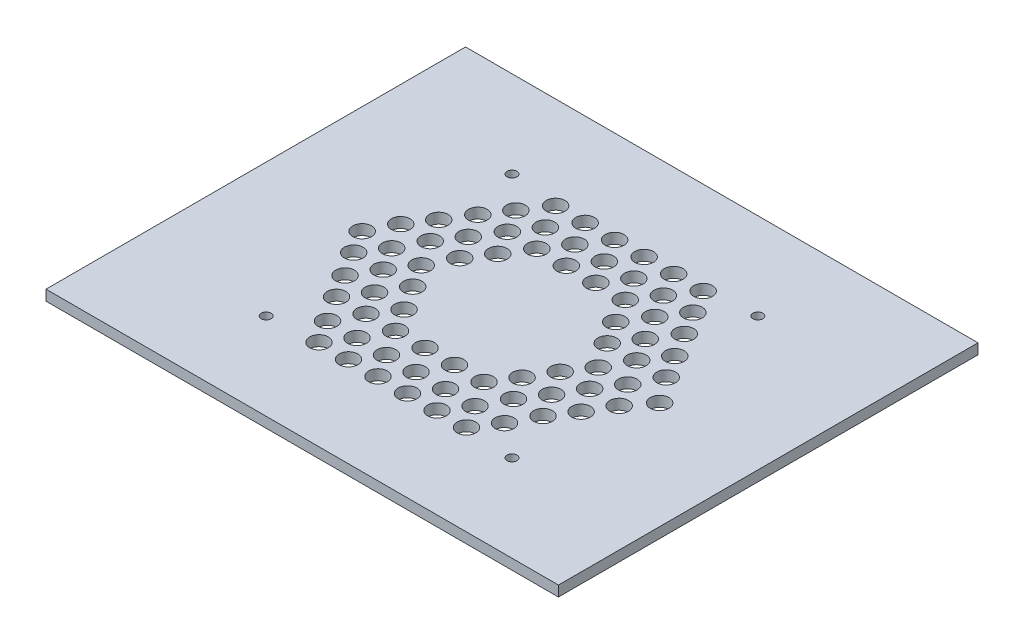
from build123d import *

# Parameters (mm, degrees)
SKETCH1_W           = 156.35
SKETCH1_H           = 128
BOSS_EXTRUDE1_DEPTH = 3.175
SKETCH2_R           = 1.5
CUT_EXTRUDE1_DEPTH  = 10
SKETCH3_R           = 2.8575
CUT_EXTRUDE2_DEPTH  = 10


with BuildPart() as part:
    # Sketch1 → Boss-Extrude1 (new body)
    with BuildSketch(Plane(origin=(0, 0, 0), x_dir=(1, 0, 0), z_dir=(0, 1, 0))):
        with Locations((16.313207547, -20.741037736)):
            Rectangle(SKETCH1_W, SKETCH1_H)
    extrude(amount=BOSS_EXTRUDE1_DEPTH)

    # Sketch2 → Cut-Extrude1 (cut)
    with BuildSketch(Plane.XZ):
        with Locations((-21.186792453, 58.241037736)):
            Circle(SKETCH2_R)
        with Locations((53.813207547, 58.241037736)):
            Circle(SKETCH2_R)
        with Locations((53.813207547, -16.758962264)):
            Circle(SKETCH2_R)
        with Locations((-21.186792453, -16.758962264)):
            Circle(SKETCH2_R)
    extrude(amount=-CUT_EXTRUDE1_DEPTH, mode=Mode.SUBTRACT)

    # Sketch3 → Cut-Extrude2 (cut)
    with BuildSketch(Plane.XZ):
        with Locations((-6.178033112, 57.136048301)):
            Circle(SKETCH3_R)
        with Locations((2.821966888, 57.136048301)):
            Circle(SKETCH3_R)
        with Locations((11.821966888, 57.136048301)):
            Circle(SKETCH3_R)
        with Locations((20.821966888, 57.136048301)):
            Circle(SKETCH3_R)
        with Locations((29.821966888, 57.136048301)):
            Circle(SKETCH3_R)
        with Locations((38.821966888, 57.136048301)):
            Circle(SKETCH3_R)
        with Locations((-10.513543723, 50.195532798)):
            Circle(SKETCH3_R)
        with Locations((-1.513543723, 50.195532798)):
            Circle(SKETCH3_R)
        with Locations((7.486456277, 50.195532798)):
            Circle(SKETCH3_R)
        with Locations((16.486456277, 50.195532798)):
            Circle(SKETCH3_R)
        with Locations((25.486456277, 50.195532798)):
            Circle(SKETCH3_R)
        with Locations((34.486456277, 50.195532798)):
            Circle(SKETCH3_R)
        with Locations((43.486456277, 50.195532798)):
            Circle(SKETCH3_R)
        with Locations((-15.52660687, 42.439711518)):
            Circle(SKETCH3_R)
        with Locations((-6.52660687, 42.439711518)):
            Circle(SKETCH3_R)
        with Locations((2.47339313, 42.439711518)):
            Circle(SKETCH3_R)
        with Locations((11.47339313, 42.439711518)):
            Circle(SKETCH3_R)
        with Locations((20.47339313, 42.439711518)):
            Circle(SKETCH3_R)
        with Locations((29.47339313, 42.439711518)):
            Circle(SKETCH3_R)
        with Locations((38.47339313, 42.439711518)):
            Circle(SKETCH3_R)
        with Locations((47.47339313, 42.439711518)):
            Circle(SKETCH3_R)
        with Locations((-19.862117481, 35.499196015)):
            Circle(SKETCH3_R)
        with Locations((-10.862117481, 35.499196015)):
            Circle(SKETCH3_R)
        with Locations((-1.862117481, 35.499196015)):
            Circle(SKETCH3_R)
        with Locations((34.137882519, 35.499196015)):
            Circle(SKETCH3_R)
        with Locations((43.137882519, 35.499196015)):
            Circle(SKETCH3_R)
        with Locations((52.137882519, 35.499196015)):
            Circle(SKETCH3_R)
        with Locations((-24.594118133, 28.137585821)):
            Circle(SKETCH3_R)
        with Locations((-15.594118133, 28.137585821)):
            Circle(SKETCH3_R)
        with Locations((-6.594118133, 28.137585821)):
            Circle(SKETCH3_R)
        with Locations((38.405881867, 28.137585821)):
            Circle(SKETCH3_R)
        with Locations((47.405881867, 28.137585821)):
            Circle(SKETCH3_R)
        with Locations((56.405881867, 28.137585821)):
            Circle(SKETCH3_R)
        with Locations((-28.929628744, 21.197070319)):
            Circle(SKETCH3_R)
        with Locations((-19.929628744, 21.197070319)):
            Circle(SKETCH3_R)
        with Locations((-10.929628744, 21.197070319)):
            Circle(SKETCH3_R)
        with Locations((43.070371256, 21.197070319)):
            Circle(SKETCH3_R)
        with Locations((52.070371256, 21.197070319)):
            Circle(SKETCH3_R)
        with Locations((-24.942691891, 13.441249039)):
            Circle(SKETCH3_R)
        with Locations((-15.942691891, 13.441249039)):
            Circle(SKETCH3_R)
        with Locations((-6.942691891, 13.441249039)):
            Circle(SKETCH3_R)
        with Locations((38.057308109, 13.441249039)):
            Circle(SKETCH3_R)
        with Locations((47.057308109, 13.441249039)):
            Circle(SKETCH3_R)
        with Locations((56.057308109, 13.441249039)):
            Circle(SKETCH3_R)
        with Locations((-20.278202502, 6.500733536)):
            Circle(SKETCH3_R)
        with Locations((-11.278202502, 6.500733536)):
            Circle(SKETCH3_R)
        with Locations((-2.278202502, 6.500733536)):
            Circle(SKETCH3_R)
        with Locations((33.721797498, 6.500733536)):
            Circle(SKETCH3_R)
        with Locations((42.721797498, 6.500733536)):
            Circle(SKETCH3_R)
        with Locations((51.721797498, 6.500733536)):
            Circle(SKETCH3_R)
        with Locations((-15.662214589, -0.805516952)):
            Circle(SKETCH3_R)
        with Locations((-6.662214589, -0.805516952)):
            Circle(SKETCH3_R)
        with Locations((2.337785411, -0.805516952)):
            Circle(SKETCH3_R)
        with Locations((11.337785411, -0.805516952)):
            Circle(SKETCH3_R)
        with Locations((20.337785411, -0.805516952)):
            Circle(SKETCH3_R)
        with Locations((29.337785411, -0.805516952)):
            Circle(SKETCH3_R)
        with Locations((38.337785411, -0.805516952)):
            Circle(SKETCH3_R)
        with Locations((47.337785411, -0.805516952)):
            Circle(SKETCH3_R)
        with Locations((-10.9977252, -7.746032454)):
            Circle(SKETCH3_R)
        with Locations((-1.9977252, -7.746032454)):
            Circle(SKETCH3_R)
        with Locations((7.0022748, -7.746032454)):
            Circle(SKETCH3_R)
        with Locations((16.0022748, -7.746032454)):
            Circle(SKETCH3_R)
        with Locations((25.0022748, -7.746032454)):
            Circle(SKETCH3_R)
        with Locations((34.0022748, -7.746032454)):
            Circle(SKETCH3_R)
        with Locations((43.0022748, -7.746032454)):
            Circle(SKETCH3_R)
        with Locations((-6.137528578, -15.018990423)):
            Circle(SKETCH3_R)
        with Locations((2.862471422, -15.018990423)):
            Circle(SKETCH3_R)
        with Locations((11.862471422, -15.018990423)):
            Circle(SKETCH3_R)
        with Locations((20.862471422, -15.018990423)):
            Circle(SKETCH3_R)
        with Locations((29.862471422, -15.018990423)):
            Circle(SKETCH3_R)
        with Locations((38.862471422, -15.018990423)):
            Circle(SKETCH3_R)
        with Locations((61.811516702, 21.197070319)):
            Circle(SKETCH3_R)
    extrude(amount=-CUT_EXTRUDE2_DEPTH, mode=Mode.SUBTRACT)


solid = part.part
